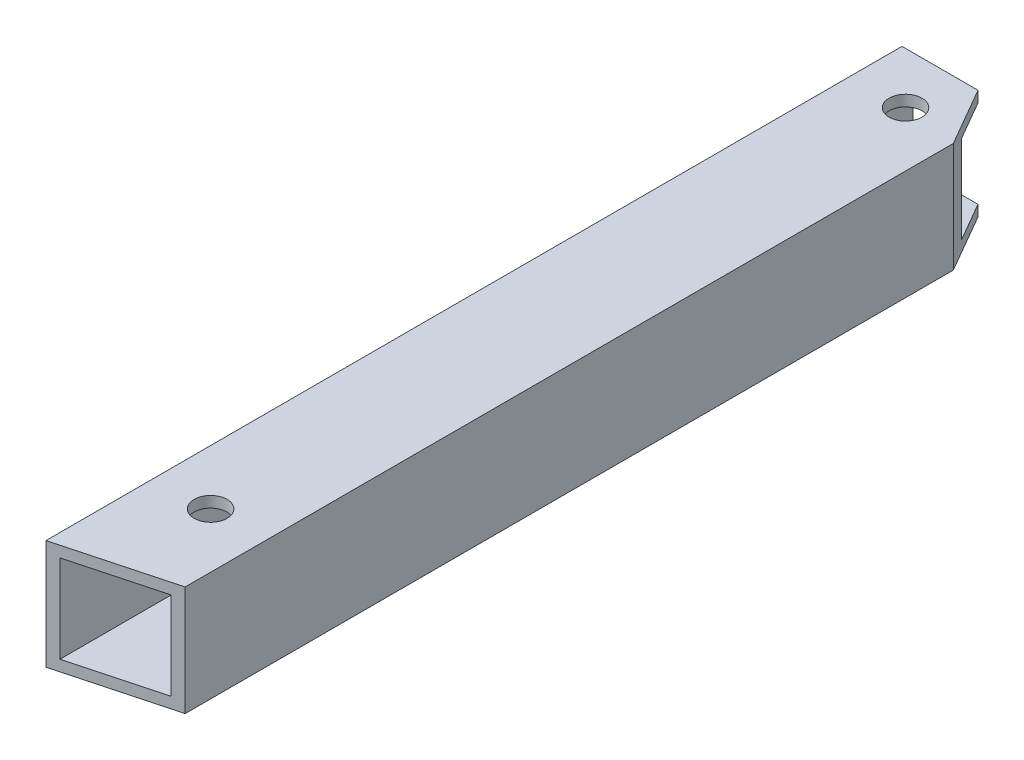
from build123d import *

# Parameters (mm, degrees)
SKETCH_1_W          = 10
SKETCH_1_H          = 10
SKETCH_1_W_2        = 8
SKETCH_1_H_2        = 8
EXTRUDE_1_DEPTH     = 90
SKETCH_2_R          = 1.5
CUT_EXTRUDE_1_DEPTH = 11


with BuildPart() as part:
    # 草图1 → 拉伸-薄壁1 (new body)
    with BuildSketch(Plane.XY):
        Rectangle(SKETCH_1_W, SKETCH_1_H)
        Rectangle(SKETCH_1_W_2, SKETCH_1_H_2, mode=Mode.SUBTRACT)
    extrude(amount=EXTRUDE_1_DEPTH)

    # 草图2 → 切除-拉伸1 (cut, through all)
    with BuildSketch(Plane.XZ.offset(5)):
        Polygon((1.92820323, 12), (-5, 0), (5, 0), (5, 17.320508076), align=None)
        Polygon((-5, 12), (-5, 0), (1.92820323, 12), align=None)
        with Locations((0, 16.676515813)):
            Circle(SKETCH_2_R)
        Polygon((5, 90), (-5, 90), (5, 87.320508076), align=None)
        with Locations((0, 80)):
            Circle(SKETCH_2_R)
    extrude(amount=-CUT_EXTRUDE_1_DEPTH, mode=Mode.SUBTRACT)


solid = part.part
